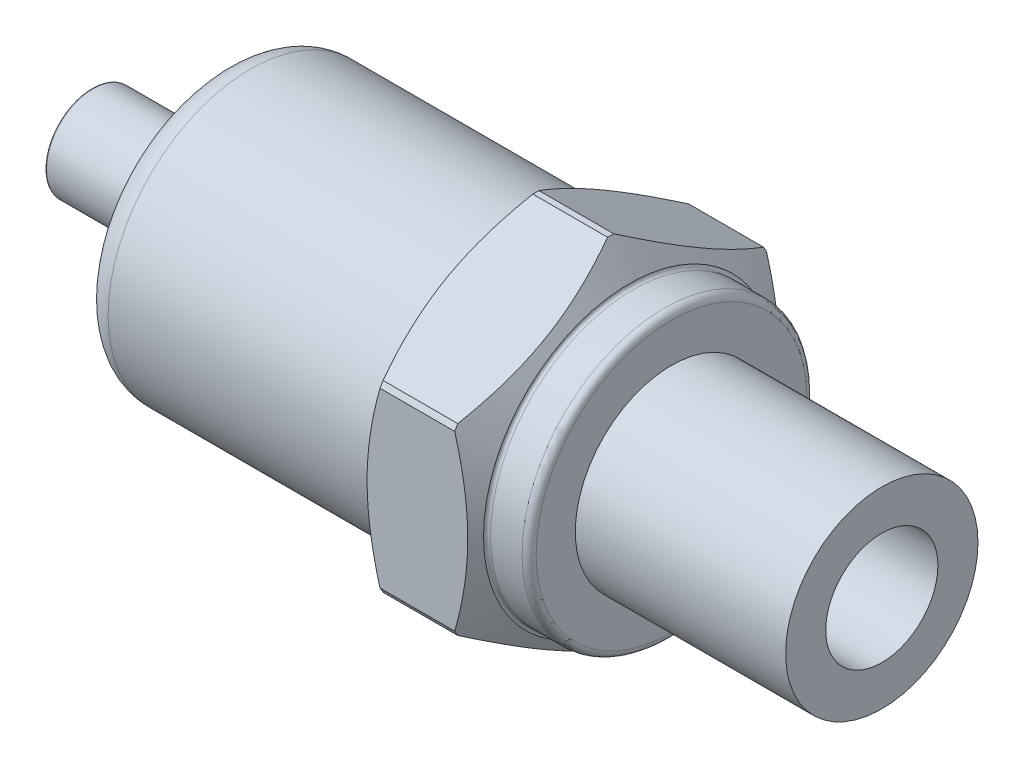
from build123d import *

# Parameters (mm, degrees)
BOSS_EXTRUDE1_DEPTH  = 8
SKETCH2_R            = 10.15
BOSS_EXTRUDE2_DEPTH  = 3
SKETCH3_R            = 10.15
BOSS_EXTRUDE3_DEPTH  = 20.32
SKETCH4_R            = 3.335
BOSS_EXTRUDE4_DEPTH  = 3
SKETCH6_R            = 3.335
BOSS_EXTRUDE5_DEPTH  = 7
FILLET1_R            = 0.1
FILLET2_R            = 0.5
FILLET3_R            = 2
FILLET4_R            = 0.25
CHAMFER1_SIZE        = 0.25
CHAMFER1_EDGE_2_SIZE = 0.25
CHAMFER1_EDGE_3_SIZE = 0.25
CHAMFER1_EDGE_4_SIZE = 0.25
CHAMFER1_EDGE_5_SIZE = 0.25
CHAMFER1_EDGE_6_SIZE = 0.25
SKETCH7_R            = 6.858
BOSS_EXTRUDE6_DEPTH  = 15
SKETCH12_R           = 4
CUT_EXTRUDE1_DEPTH   = 15
FILLET5_R            = 0.5
SKETCH13_R           = 2.245309126
CUT_EXTRUDE2_DEPTH   = 7
SKETCH14_OUTSIDE_W   = 72.004
SKETCH14_OUTSIDE_H   = 75.192
SKETCH14_OUTSIDE_R   = 10.4
CUT_EXTRUDE5_DEPTH   = 10
CUT_EXTRUDE5_DRAFT   = -60
SKETCH15_OUTSIDE_W   = 72.004
SKETCH15_OUTSIDE_H   = 75.192
SKETCH15_OUTSIDE_R   = 10.4
CUT_EXTRUDE6_DEPTH   = 10
CUT_EXTRUDE6_DRAFT   = -60


with BuildPart() as part:
    # Sketch1 → Boss-Extrude1 (new body)
    with BuildSketch(Plane(origin=(0, 0, 0), x_dir=(0, 0, -1), z_dir=(1, 0, 0))):
        Polygon((11.115, -6.417248242), (11.115, 6.417248242), (0, 12.834496484), (-11.115, 6.417248242), (-11.115, -6.417248242), (0, -12.834496484), align=None)
    extrude(amount=BOSS_EXTRUDE1_DEPTH)

    # Sketch2 → Boss-Extrude2 (add)
    with BuildSketch(Plane(origin=(8, 0, 0), x_dir=(0, 0, -1), z_dir=(1, 0, 0))):
        Circle(SKETCH2_R)
    extrude(amount=BOSS_EXTRUDE2_DEPTH)

    # Sketch3 → Boss-Extrude3 (add)
    with BuildSketch(Plane.ZY):
        with Locations(Location((0, 0, 0), (0, 0, 180))):
            Circle(SKETCH3_R)
    extrude(amount=BOSS_EXTRUDE3_DEPTH)

    # Sketch4 → Boss-Extrude4 (add)
    with BuildSketch(Plane.ZY.offset(20.32)):
        Circle(SKETCH4_R)
    extrude(amount=BOSS_EXTRUDE4_DEPTH)

    # loft up to a face of the part (loft1)
    loft([Face(Wire([part.edges().sort_by_distance((-20.32, -7.399031568, 6.948153125))[0]])), Face(Wire([part.edges().sort_by_distance((-23.32, 2.431110372, -2.282964598))[0]]))])

    # Sketch6 → Boss-Extrude5 (add)
    with BuildSketch(Plane.ZY.offset(23.32)):
        with Locations(Location((0, 0, 0), (0, 0, 180))):
            Circle(SKETCH6_R)
    extrude(amount=BOSS_EXTRUDE5_DEPTH)

    # Fillet1
    fillet1_edges = [part.edges().sort_by_distance(p)[0] for p in [
        (-30.32, 0, 3.335),
    ]]
    fillet(fillet1_edges, radius=FILLET1_R)

    # Fillet2
    fillet2_edges = [part.edges().sort_by_distance(p)[0] for p in [
        (-23.32, 0, 3.335),
    ]]
    fillet(fillet2_edges, radius=FILLET2_R)

    # Fillet3
    fillet3_edges = [part.edges().sort_by_distance(p)[0] for p in [
        (-20.32, 0, 10.15),
    ]]
    fillet(fillet3_edges, radius=FILLET3_R)

    # Fillet4
    fillet4_edges = [part.edges().sort_by_distance(p)[0] for p in [
        (8, 0, 10.15),
        (0, 0, 10.15),
    ]]
    fillet(fillet4_edges, radius=FILLET4_R)

    # Chamfer1
    chamfer1_edges = [part.edges().sort_by_distance(p)[0] for p in [
        (4, -12.834496484, 0),
    ]]
    chamfer(chamfer1_edges, length=CHAMFER1_SIZE)

    # Chamfer1 edge 2
    chamfer1_edge_2_edges = [part.edges().sort_by_distance(p)[0] for p in [
        (4, -6.417248242, 11.115),
    ]]
    chamfer(chamfer1_edge_2_edges, length=CHAMFER1_EDGE_2_SIZE)

    # Chamfer1 edge 3
    chamfer1_edge_3_edges = [part.edges().sort_by_distance(p)[0] for p in [
        (4, 6.417248242, 11.115),
    ]]
    chamfer(chamfer1_edge_3_edges, length=CHAMFER1_EDGE_3_SIZE)

    # Chamfer1 edge 4
    chamfer1_edge_4_edges = [part.edges().sort_by_distance(p)[0] for p in [
        (4, 12.834496484, 0),
    ]]
    chamfer(chamfer1_edge_4_edges, length=CHAMFER1_EDGE_4_SIZE)

    # Chamfer1 edge 5
    chamfer1_edge_5_edges = [part.edges().sort_by_distance(p)[0] for p in [
        (4, 6.417248242, -11.115),
    ]]
    chamfer(chamfer1_edge_5_edges, length=CHAMFER1_EDGE_5_SIZE)

    # Chamfer1 edge 6
    chamfer1_edge_6_edges = [part.edges().sort_by_distance(p)[0] for p in [
        (4, -6.417248242, -11.115),
    ]]
    chamfer(chamfer1_edge_6_edges, length=CHAMFER1_EDGE_6_SIZE)

    # Sketch7 → Boss-Extrude6 (add)
    with BuildSketch(Plane(origin=(11, 0, 0), x_dir=(0, 0, -1), z_dir=(1, 0, 0))):
        Circle(SKETCH7_R)
    extrude(amount=BOSS_EXTRUDE6_DEPTH)

    # Sketch12 → Cut-Extrude1 (cut)
    with BuildSketch(Plane(origin=(26, 0, 0), x_dir=(0, 0, -1), z_dir=(1, 0, 0))):
        Circle(SKETCH12_R)
    extrude(amount=-CUT_EXTRUDE1_DEPTH, mode=Mode.SUBTRACT)

    # Fillet5
    fillet5_edges = [part.edges().sort_by_distance(p)[0] for p in [
        (11, 0, 10.15),
    ]]
    fillet(fillet5_edges, radius=FILLET5_R)

    # Sketch13 → Cut-Extrude2 (cut)
    with BuildSketch(Plane.ZY.offset(30.32)):
        Circle(SKETCH13_R)
    extrude(amount=-CUT_EXTRUDE2_DEPTH, mode=Mode.SUBTRACT)


with BuildPart() as cut_extrude5_tool:
    # Sketch14 outside → Cut-Extrude5 (with draft: the straight prism first)
    with BuildSketch(Plane(origin=(8, 0, 0), x_dir=(0, 0, -1), z_dir=(1, 0, 0))):
        Rectangle(SKETCH14_OUTSIDE_W, SKETCH14_OUTSIDE_H)
        Circle(SKETCH14_OUTSIDE_R, mode=Mode.SUBTRACT)
    extrude(amount=-CUT_EXTRUDE5_DEPTH)
    # Cut-Extrude5: the draft: its side faces are tilted about the plane it starts from
    cut_extrude5_sides = [cut_extrude5_tool.faces().sort_by_distance(p)[0] for p in [
        (3, -37.596, 0),
        (3, 0, -36.002),
        (3, 37.596, 0),
        (3, 0, 36.002),
        (3, 0, 10.4),
    ]]
    draft(cut_extrude5_sides, Plane(origin=(8, 0, 0), x_dir=(0, 0, -1), z_dir=(1, 0, 0)), CUT_EXTRUDE5_DRAFT)


with BuildPart() as part_1:
    add(part.part)

    # Cut-Extrude5: cut by cut_extrude5_tool
    add(cut_extrude5_tool.part, mode=Mode.SUBTRACT)


with BuildPart() as cut_extrude6_tool:
    # Sketch15 outside → Cut-Extrude6 (with draft: the straight prism first)
    with BuildSketch(Plane.ZY):
        Rectangle(SKETCH15_OUTSIDE_W, SKETCH15_OUTSIDE_H)
        Circle(SKETCH15_OUTSIDE_R, mode=Mode.SUBTRACT)
    extrude(amount=-CUT_EXTRUDE6_DEPTH)
    # Cut-Extrude6: the draft: its side faces are tilted about the plane it starts from
    cut_extrude6_sides = [cut_extrude6_tool.faces().sort_by_distance(p)[0] for p in [
        (5, -37.596, 0),
        (5, 0, 36.002),
        (5, 37.596, 0),
        (5, 0, -36.002),
        (5, 0, -10.4),
    ]]
    draft(cut_extrude6_sides, Plane.ZY, CUT_EXTRUDE6_DRAFT)


with BuildPart() as part_2:
    add(part_1.part)

    # Cut-Extrude6: cut by cut_extrude6_tool
    add(cut_extrude6_tool.part, mode=Mode.SUBTRACT)


solid = part_2.part
